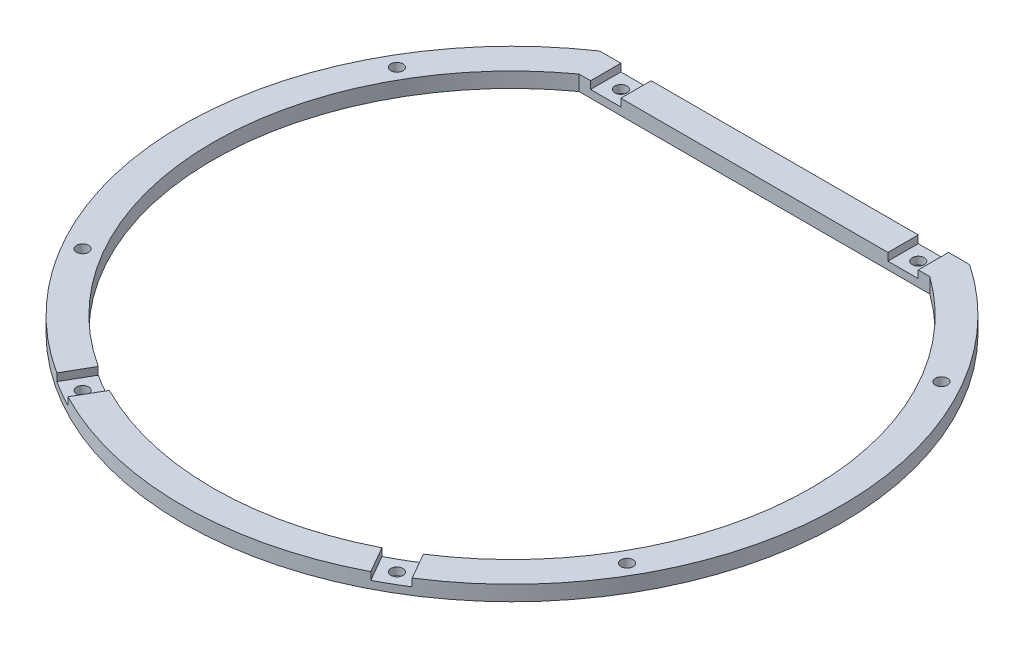
from build123d import *

# Parameters (mm, degrees)
BOSS_EXTRUDE1_DEPTH  = 4
SKETCH2_W            = 8
SKETCH2_H            = 8
CUT_EXTRUDE1_DEPTH   = 2
M3_CLEARANCE_HOLE1_D = 3.2


with BuildPart() as part:
    # Sketch1 → Boss-Extrude1 (new body)
    with BuildSketch(Plane(origin=(0, 0, 0), x_dir=(1, 0, 0), z_dir=(0, 1, 0))):
        with BuildLine():
            Line((-48.836461788, 72), (48.836461788, 72))
            ThreePointArc((48.836461788, 72), (0, -87), (-48.836461788, 72))
        make_face()
        with BuildLine():
            Line((-46.314144708, 64), (46.314144708, 64))
            ThreePointArc((46.314144708, 64), (0, -79), (-46.314144708, 64))
        make_face(mode=Mode.SUBTRACT)
    extrude(amount=BOSS_EXTRUDE1_DEPTH)

    # Sketch2 → Cut-Extrude1 (cut)
    with BuildSketch(Plane(origin=(0, 4, 0), x_dir=(1, 0, 0), z_dir=(0, 1, 0))):
        with Locations((-39.259818305, 68)):
            Rectangle(SKETCH2_W, SKETCH2_H)
        with Locations((39.259818305, 68)):
            Rectangle(SKETCH2_W, SKETCH2_H)
        Polygon((-53.75822561, -85.111978082), (-34.446229734, -51.662620029), (-27.518026504, -55.662620029), (-46.83002238, -89.111978082), align=None)
    cut_extrude1 = extrude(amount=-CUT_EXTRUDE1_DEPTH, mode=Mode.SUBTRACT)

    # Mirror1: Cut-Extrude1 across plane
    add(cut_extrude1.mirror(Plane(origin=(0, 0, 0), x_dir=(0, 0, 1), z_dir=(1, 0, 0))), mode=Mode.SUBTRACT)

    # M3 Clearance Hole1 (through all)
    with Locations(Plane(origin=(71.880108514, 4, 41.5), x_dir=(0, 0, 1), z_dir=(0, 1, 0))):
        with Locations((0, 0), (30.380108514, -30.380108514), (30.380108514, -113.380108514), (-83, -143.760217028), (0, -143.760217028), (-83, 0), (-109.5, -111.139926819), (-109.5, -32.620290209)):
            Hole(M3_CLEARANCE_HOLE1_D / 2)


solid = part.part
